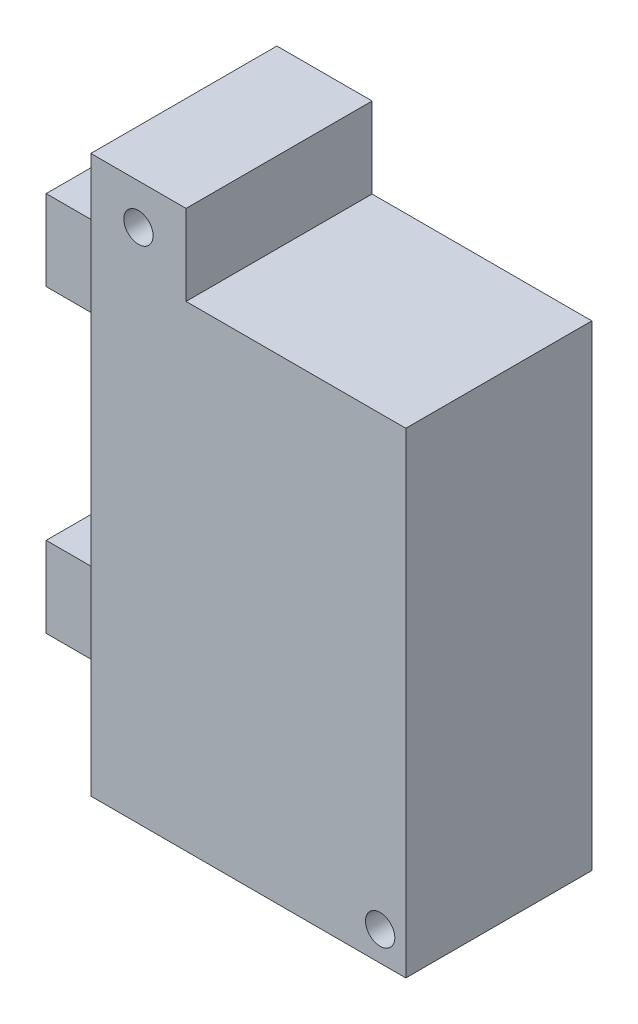
from build123d import *

# Parameters (mm, degrees)
CROQUIS1_R              = 2
SALIENTE_EXTRUIR1_DEPTH = 12.7
CROQUIS2_W              = 10.3
CROQUIS2_H              = 11
SALIENTE_EXTRUIR2_DEPTH = 8.5
CROQUIS3_R              = 3
CORTAR_EXTRUIR1_DEPTH   = 9.5


with BuildPart() as part:
    # Croquis1 → Saliente-Extruir1 (new body, symmetric)
    with BuildSketch(Plane.XY):
        Polygon((13, 65), (43, 65), (43, 0), (0, 0), (0, 65), (0, 76), (13, 76), align=None)
        with Locations((39.5, 4)):
            Circle(CROQUIS1_R, mode=Mode.SUBTRACT)
        with Locations((6.5, 70.5)):
            Circle(CROQUIS1_R, mode=Mode.SUBTRACT)
    extrude(amount=SALIENTE_EXTRUIR1_DEPTH, both=True)

    # Croquis2 → Saliente-Extruir2 (add, symmetric)
    with BuildSketch(Plane.XY):
        with Locations((-5.15, 58.5)):
            Rectangle(CROQUIS2_W, CROQUIS2_H)
        with Locations((-5.15, 17.5)):
            Rectangle(CROQUIS2_W, CROQUIS2_H)
    extrude(amount=SALIENTE_EXTRUIR2_DEPTH, both=True)

    # Croquis3 → Cortar-Extruir1 (cut)
    with BuildSketch(Plane.ZY.offset(10.3)):
        with Locations((0, 58.5)):
            Circle(CROQUIS3_R)
        with Locations((0, 17.5)):
            Circle(CROQUIS3_R)
    extrude(amount=-CORTAR_EXTRUIR1_DEPTH, mode=Mode.SUBTRACT)


solid = part.part
